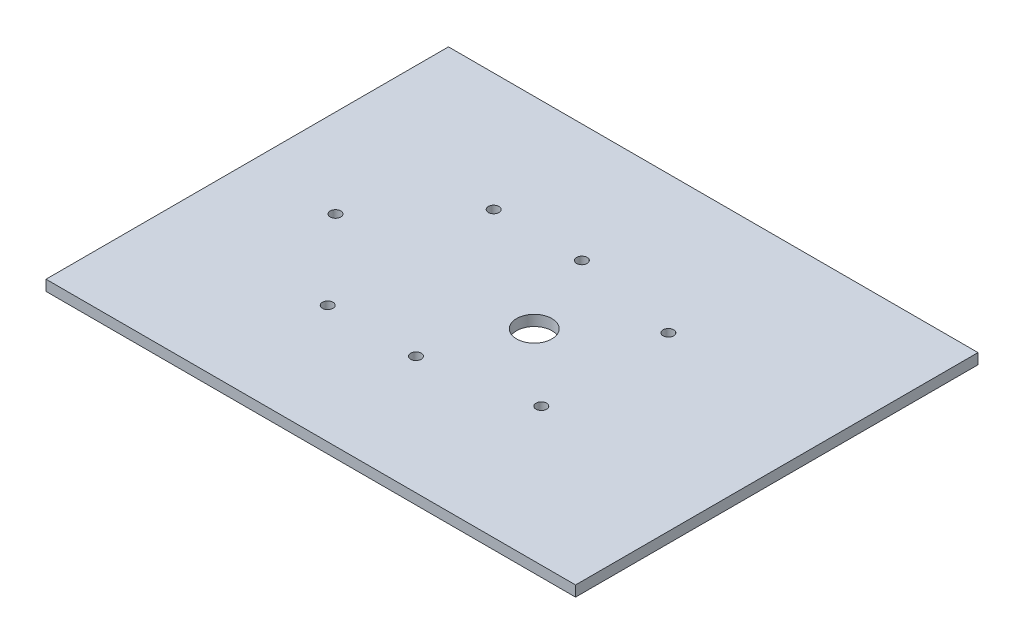
from build123d import *

# Parameters (mm, degrees)
SKETCH_1_W          = 150
SKETCH_1_H          = 114
EXTRUDE_1_DEPTH     = 3
SKETCH_2_R          = 1.5
SKETCH_2_R_2        = 5
CUT_EXTRUDE_1_DEPTH = 3


with BuildPart() as part:
    # 草图1 → 凸台-拉伸1 (new body)
    with BuildSketch(Plane(origin=(0, 0, 0), x_dir=(1, 0, 0), z_dir=(0, 1, 0))):
        with Locations((75, -57)):
            Rectangle(SKETCH_1_W, SKETCH_1_H)
    extrude(amount=EXTRUDE_1_DEPTH)

    # 草图2 → 切除-拉伸1 (cut)
    with BuildSketch(Plane(origin=(0, 3, 0), x_dir=(1, 0, 0), z_dir=(0, 1, 0))):
        with Locations((25, -57)):
            Circle(SKETCH_2_R)
        with Locations((101.3, -75)):
            Circle(SKETCH_2_R)
        with Locations((101.3, -39)):
            Circle(SKETCH_2_R)
        with Locations((71.3, -80.5)):
            Circle(SKETCH_2_R)
        with Locations((46.3, -80.5)):
            Circle(SKETCH_2_R)
        with Locations((71.3, -33.5)):
            Circle(SKETCH_2_R)
        with Locations((46.3, -33.5)):
            Circle(SKETCH_2_R)
        with Locations((81.3, -57)):
            Circle(SKETCH_2_R_2)
    extrude(amount=-CUT_EXTRUDE_1_DEPTH, mode=Mode.SUBTRACT)


solid = part.part
